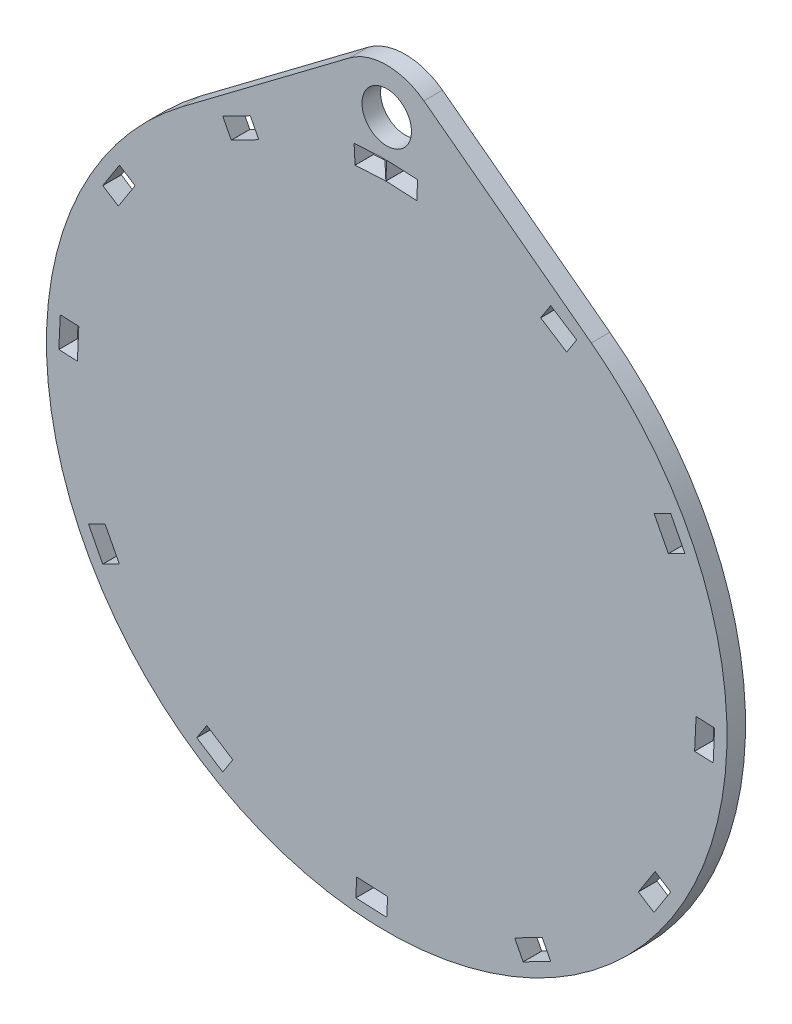
from build123d import *

# Parameters (mm, degrees)
SKETCH1_R           = 4
BOSS_EXTRUDE2_DEPTH = 3


with BuildPart() as part:
    # Sketch1 → Boss-Extrude2 (new body)
    with BuildSketch(Plane.XY):
        with BuildLine():
            Line((-6.012571554, 64.307027075), (-33.069131887, 43.948066126))
            ThreePointArc((-33.069131887, 43.948066126), (2.07e-06, -55), (33.069128578, 43.948068616))
            Line((33.069128578, 43.948068616), (6.012566712, 64.307027528))
            ThreePointArc((6.012566712, 64.307027528), (-2.497e-06, 66.316469598), (-6.012571554, 64.307027075))
        make_face()
        with BuildLine():
            ThreePointArc((-30.698965133, -43.203238849), (-30.703332787, -43.196953768), (-30.701976961, -43.189421147))
            Line((-30.701976961, -43.189421147), (-29.091901743, -40.68182114))
            ThreePointArc((-29.091901743, -40.68182114), (-29.085616662, -40.677453486), (-29.078084041, -40.678809312))
            Line((-29.078084041, -40.678809312), (-24.88753101, -43.369471925))
            ThreePointArc((-24.88753101, -43.369471925), (-24.883163356, -43.375757006), (-24.884519182, -43.383289627))
            Line((-24.884519182, -43.383289627), (-26.4945944, -45.890889633))
            ThreePointArc((-26.4945944, -45.890889633), (-26.500879481, -45.895257287), (-26.508412102, -45.893901462))
            Line((-26.508412102, -45.893901462), (-30.698965133, -43.203238849))
        make_face(mode=Mode.SUBTRACT)
        with BuildLine():
            ThreePointArc((-4.98444277, -52.764580253), (-4.99136781, -52.76132104), (-4.993959941, -52.754119686))
            Line((-4.993959941, -52.754119686), (-4.853393903, -49.777436769))
            ThreePointArc((-4.853393903, -49.777436769), (-4.85013469, -49.770511729), (-4.842933336, -49.767919598))
            Line((-4.842933336, -49.767919598), (0.131523351, -50.002825259))
            ThreePointArc((0.131523351, -50.002825259), (0.138448391, -50.006084472), (0.141040522, -50.013285826))
            Line((0.141040522, -50.013285826), (0.000474484, -52.989968743))
            ThreePointArc((0.000474484, -52.989968743), (-0.002784729, -52.996893783), (-0.009986083, -52.999485914))
            Line((-0.009986083, -52.999485914), (-4.98444277, -52.764580253))
        make_face(mode=Mode.SUBTRACT)
        with BuildLine():
            ThreePointArc((-48.187724044, -22.065613117), (-48.188364003, -22.05798625), (-48.183423512, -22.052140721))
            Line((-48.183423512, -22.052140721), (-45.535257468, -20.685533022))
            ThreePointArc((-45.535257468, -20.685533022), (-45.527630602, -20.684893064), (-45.521785073, -20.689833554))
            Line((-45.521785073, -20.689833554), (-43.237990999, -25.115292245))
            ThreePointArc((-43.237990999, -25.115292245), (-43.23735104, -25.122919112), (-43.242291531, -25.12876464))
            Line((-43.242291531, -25.12876464), (-45.890457575, -26.495372339))
            ThreePointArc((-45.890457575, -26.495372339), (-45.898084441, -26.496012298), (-45.90392997, -26.491071808))
            Line((-45.90392997, -26.491071808), (-48.187724044, -22.065613117))
        make_face(mode=Mode.SUBTRACT)
        with BuildLine():
            ThreePointArc((-52.764620675, 4.984487199), (-52.761361462, 4.991412238), (-52.754160108, 4.994004369))
            Line((-52.754160108, 4.994004369), (-49.777477191, 4.853438332))
            ThreePointArc((-49.777477191, 4.853438332), (-49.770552151, 4.850179119), (-49.76796002, 4.842977765))
            Line((-49.76796002, 4.842977765), (-50.002865681, -0.131478922))
            ThreePointArc((-50.002865681, -0.131478922), (-50.006124893, -0.138403962), (-50.013326248, -0.140996093))
            Line((-50.013326248, -0.140996093), (-52.990009165, -0.000430055))
            ThreePointArc((-52.990009165, -0.000430055), (-52.996934204, 0.002829158), (-52.999526335, 0.010030512))
            Line((-52.999526335, 0.010030512), (-52.764620675, 4.984487199))
        make_face(mode=Mode.SUBTRACT)
        with BuildLine():
            ThreePointArc((22.065657545, -48.187683622), (22.058030679, -48.188323581), (22.05218515, -48.183383091))
            Line((22.05218515, -48.183383091), (20.685577451, -45.535217046))
            ThreePointArc((20.685577451, -45.535217046), (20.684937492, -45.52759018), (20.689877983, -45.521744651))
            Line((20.689877983, -45.521744651), (25.115336674, -43.237950577))
            ThreePointArc((25.115336674, -43.237950577), (25.12296354, -43.237310619), (25.128809069, -43.242251109))
            Line((25.128809069, -43.242251109), (26.495416768, -45.890417153))
            ThreePointArc((26.495416768, -45.890417153), (26.496056726, -45.898044019), (26.491116236, -45.903889548))
            Line((26.491116236, -45.903889548), (22.065657545, -48.187683622))
        make_face(mode=Mode.SUBTRACT)
        with BuildLine():
            ThreePointArc((43.203283277, -30.698924711), (43.196998196, -30.703292365), (43.189465575, -30.701936539))
            Line((43.189465575, -30.701936539), (40.681865569, -29.091861321))
            ThreePointArc((40.681865569, -29.091861321), (40.677497915, -29.08557624), (40.678853741, -29.078043619))
            Line((40.678853741, -29.078043619), (43.369516354, -24.887490588))
            ThreePointArc((43.369516354, -24.887490588), (43.375801435, -24.883122935), (43.383334056, -24.88447876))
            Line((43.383334056, -24.88447876), (45.890934062, -26.494553978))
            ThreePointArc((45.890934062, -26.494553978), (45.895301716, -26.500839059), (45.89394589, -26.508371681))
            Line((45.89394589, -26.508371681), (43.203283277, -30.698924711))
        make_face(mode=Mode.SUBTRACT)
        with BuildLine():
            ThreePointArc((52.990013172, 0.000514906), (52.996938211, -0.002744307), (52.999530342, -0.009945661))
            Line((52.999530342, -0.009945661), (52.764624682, -4.984402348))
            ThreePointArc((52.764624682, -4.984402348), (52.761365469, -4.991327388), (52.754164115, -4.993919519))
            Line((52.754164115, -4.993919519), (49.777481198, -4.853353481))
            ThreePointArc((49.777481198, -4.853353481), (49.770556158, -4.850094268), (49.767964027, -4.842892914))
            Line((49.767964027, -4.842892914), (50.002869687, 0.131563773))
            ThreePointArc((50.002869687, 0.131563773), (50.0061289, 0.138488813), (50.013330254, 0.141080944))
            Line((50.013330254, 0.141080944), (52.990013172, 0.000514906))
        make_face(mode=Mode.SUBTRACT)
        with BuildLine():
            ThreePointArc((-43.203279271, 30.699009562), (-43.19699419, 30.703377216), (-43.189461569, 30.70202139))
            Line((-43.189461569, 30.70202139), (-40.681861562, 29.091946172))
            ThreePointArc((-40.681861562, 29.091946172), (-40.677493908, 29.085661091), (-40.678849734, 29.07812847))
            Line((-40.678849734, 29.07812847), (-43.369512347, 24.887575439))
            ThreePointArc((-43.369512347, 24.887575439), (-43.375797428, 24.883207785), (-43.383330049, 24.884563611))
            Line((-43.383330049, 24.884563611), (-45.890930055, 26.494638829))
            ThreePointArc((-45.890930055, 26.494638829), (-45.895297709, 26.50092391), (-45.893941883, 26.508456531))
            Line((-45.893941883, 26.508456531), (-43.203279271, 30.699009562))
        make_face(mode=Mode.SUBTRACT)
        with BuildLine():
            ThreePointArc((-22.065653538, 48.187768473), (-22.058026672, 48.188408431), (-22.052181143, 48.183467941))
            Line((-22.052181143, 48.183467941), (-20.685573444, 45.535301897))
            ThreePointArc((-20.685573444, 45.535301897), (-20.684933486, 45.52767503), (-20.689873976, 45.521829502))
            Line((-20.689873976, 45.521829502), (-25.115332667, 43.238035428))
            ThreePointArc((-25.115332667, 43.238035428), (-25.122959534, 43.237395469), (-25.128805062, 43.242335959))
            Line((-25.128805062, 43.242335959), (-26.495412761, 45.890502003))
            ThreePointArc((-26.495412761, 45.890502003), (-26.49605272, 45.89812887), (-26.49111223, 45.903974398))
            Line((-26.49111223, 45.903974398), (-22.065653538, 48.187768473))
        make_face(mode=Mode.SUBTRACT)
        with BuildLine():
            ThreePointArc((-0.309437301, 52.998669808), (-0.302221838, 52.996117213), (-0.298924693, 52.989210153))
            Line((-0.298924693, 52.989210153), (-0.14203469, 50.013342964))
            ThreePointArc((-0.14203469, 50.013342964), (-0.144587285, 50.006127501), (-0.151494345, 50.002830356))
            Line((-0.151494345, 50.002830356), (-5.10710915, 49.741566538))
            ThreePointArc((-5.10710915, 49.741566538), (-5.114324612, 49.744119133), (-5.117621758, 49.751026193))
            Line((-5.117621758, 49.751026193), (-5.274511761, 52.726893382))
            ThreePointArc((-5.274511761, 52.726893382), (-5.271959166, 52.734108845), (-5.265052106, 52.73740599))
            Line((-5.265052106, 52.73740599), (-0.309437301, 52.998669808))
        make_face(mode=Mode.SUBTRACT)
        with Locations((0, 59)):
            Circle(SKETCH1_R, mode=Mode.SUBTRACT)
        with BuildLine():
            ThreePointArc((48.187728051, 22.065697967), (48.188368009, 22.0580711), (48.183427519, 22.052225572))
            Line((48.183427519, 22.052225572), (45.535261475, 20.685617873))
            ThreePointArc((45.535261475, 20.685617873), (45.527634608, 20.684977914), (45.52178908, 20.689918404))
            Line((45.52178908, 20.689918404), (43.237995006, 25.115377096))
            ThreePointArc((43.237995006, 25.115377096), (43.237355047, 25.123003962), (43.242295537, 25.128849491))
            Line((43.242295537, 25.128849491), (45.890461581, 26.49545719))
            ThreePointArc((45.890461581, 26.49545719), (45.898088448, 26.496097148), (45.903933977, 26.491156658))
            Line((45.903933977, 26.491156658), (48.187728051, 22.065697967))
        make_face(mode=Mode.SUBTRACT)
        with BuildLine():
            ThreePointArc((4.984446777, 52.764665104), (4.991371816, 52.761405891), (4.993963947, 52.754204537))
            Line((4.993963947, 52.754204537), (4.85339791, 49.77752162))
            ThreePointArc((4.85339791, 49.77752162), (4.850138697, 49.77059658), (4.842937343, 49.768004449))
            Line((4.842937343, 49.768004449), (-0.131519344, 50.002910109))
            ThreePointArc((-0.131519344, 50.002910109), (-0.138444384, 50.006169322), (-0.141036515, 50.013370676))
            Line((-0.141036515, 50.013370676), (-0.000470477, 52.990053593))
            ThreePointArc((-0.000470477, 52.990053593), (0.002788736, 52.996978633), (0.00999009, 52.999570764))
            Line((0.00999009, 52.999570764), (4.984446777, 52.764665104))
        make_face(mode=Mode.SUBTRACT)
        with BuildLine():
            ThreePointArc((30.69896914, 43.203323699), (30.703336794, 43.197038618), (30.701980968, 43.189505997))
            Line((30.701980968, 43.189505997), (29.09190575, 40.681905991))
            ThreePointArc((29.09190575, 40.681905991), (29.085620669, 40.677538337), (29.078088048, 40.678894163))
            Line((29.078088048, 40.678894163), (24.887535017, 43.369556776))
            ThreePointArc((24.887535017, 43.369556776), (24.883167363, 43.375841857), (24.884523189, 43.383374478))
            Line((24.884523189, 43.383374478), (26.494598407, 45.890974484))
            ThreePointArc((26.494598407, 45.890974484), (26.500883488, 45.895342138), (26.508416109, 45.893986312))
            Line((26.508416109, 45.893986312), (30.69896914, 43.203323699))
        make_face(mode=Mode.SUBTRACT)
    extrude(amount=BOSS_EXTRUDE2_DEPTH)


solid = part.part
